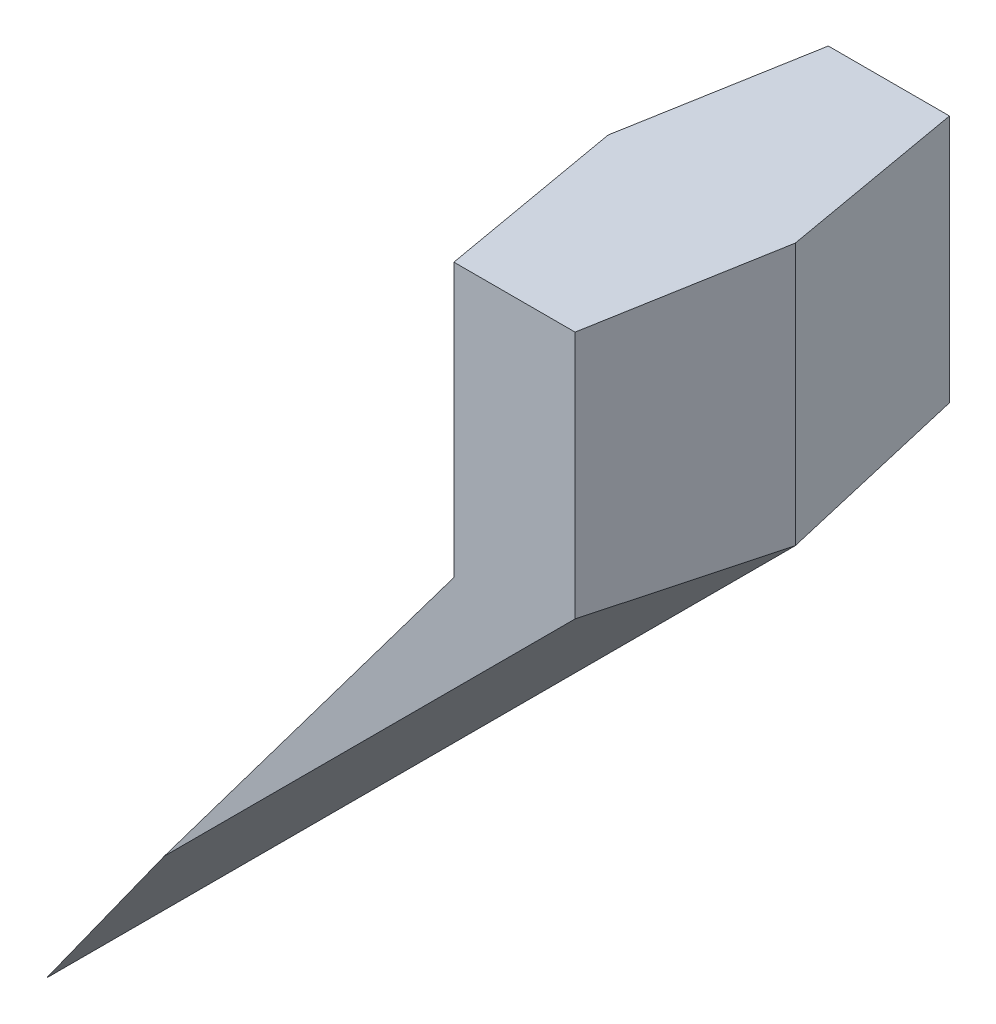
from build123d import *

# Parameters (mm, degrees)
EXTRUDE_1_DEPTH       = 10
EXTRUDE_1_DRAFT       = 10
MIRROR_1_COPY_1_DEPTH = 10
MIRROR_1_COPY_1_DRAFT = 10
SKETCH_4_W            = 44.504913076
SKETCH_4_H            = 42.19047619
CUT_EXTRUDE_4_DEPTH   = 50


with BuildPart() as part:
    # 草图2 → 凸台-拉伸1 (with draft: the straight prism first)
    with BuildSketch(Plane.XY):
        Polygon((0, 0), (-30, -40), (10, 0), (10, 20), (0, 20), align=None)
    extrude(amount=EXTRUDE_1_DEPTH)
    # 凸台-拉伸1: the draft: its side faces are tilted about the plane it starts from
    extrude_1_sides = [part.faces().sort_by_distance(p)[0] for p in [
        (-15, -20, 5),
        (-10, -20, 5),
        (10, 10, 5),
        (5, 20, 5),
        (0, 10, 5),
    ]]
    draft(extrude_1_sides, Plane.XY, EXTRUDE_1_DRAFT)


with BuildPart() as mirror_1_copy_1_tool:
    # 镜向1 copy 1 sketch → 镜向1 copy 1 (with draft: the straight prism first)
    with BuildSketch(Plane(origin=(0, 0, 0), x_dir=(1, 0, 0), z_dir=(0, 0, -1))):
        Polygon((0, 0), (-30, 40), (10, 0), (10, -20), (0, -20), align=None)
    extrude(amount=MIRROR_1_COPY_1_DEPTH)
    # 镜向1 copy 1: the draft: its side faces are tilted about the plane it starts from
    mirror_1_copy_1_sides = [mirror_1_copy_1_tool.faces().sort_by_distance(p)[0] for p in [
        (-15, -20, -5),
        (-10, -20, -5),
        (10, 10, -5),
        (5, 20, -5),
        (0, 10, -5),
    ]]
    draft(mirror_1_copy_1_sides, Plane(origin=(0, 0, 0), x_dir=(1, 0, 0), z_dir=(0, 0, -1)), MIRROR_1_COPY_1_DRAFT)


with BuildPart() as part_1:
    add(part.part)

    # 镜向1 copy 1: add mirror_1_copy_1_tool
    add(mirror_1_copy_1_tool.part)

    # 草图4 → 切除-拉伸4 (cut, symmetric)
    with BuildSketch(Plane.XY):
        with Locations((4.175676145, 35.095238095)):
            Rectangle(SKETCH_4_W, SKETCH_4_H)
    extrude(amount=CUT_EXTRUDE_4_DEPTH, both=True, mode=Mode.SUBTRACT)


solid = part_1.part
